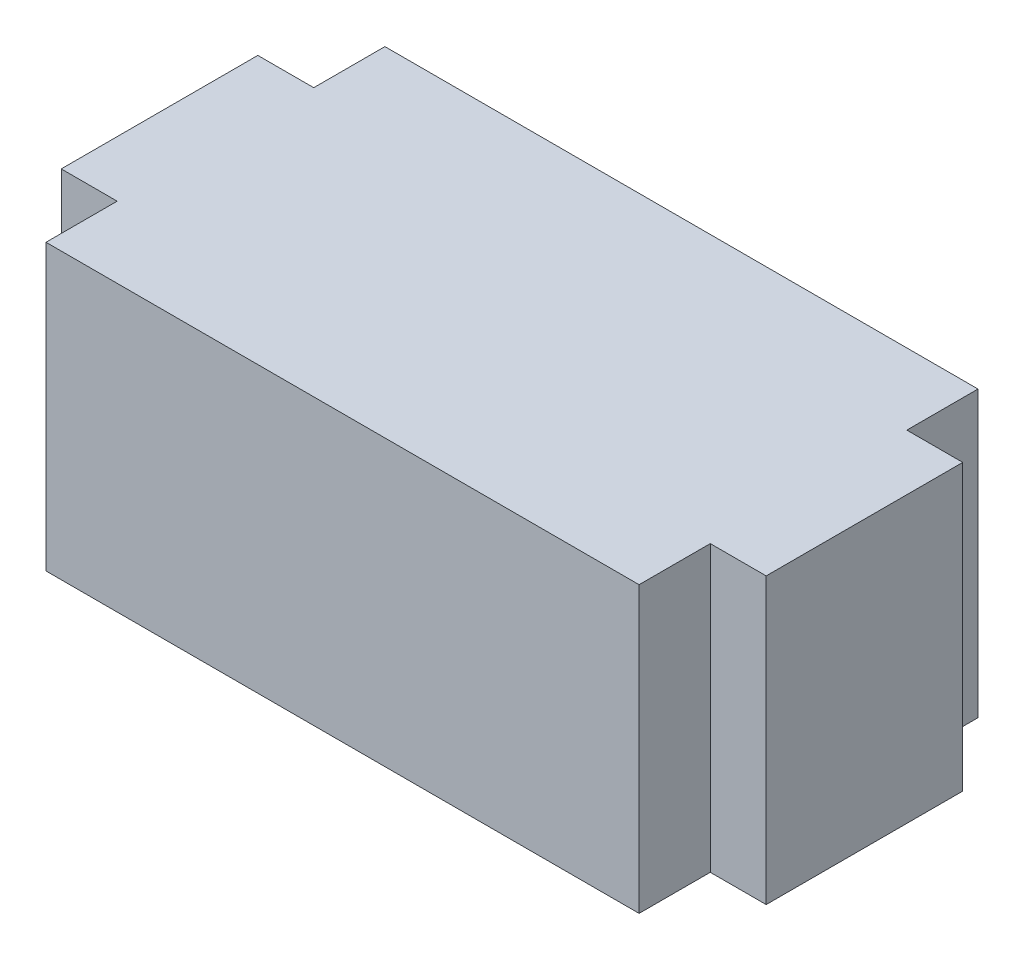
from build123d import *

# Parameters (mm, degrees)
SKETCH1_W           = 5.2
SKETCH1_H           = 2.1
BOSS_EXTRUDE1_DEPTH = 2.5
SKETCH2_W           = 0.4125
SKETCH2_H           = 0.525
CUT_EXTRUDE1_DEPTH  = 3.1


with BuildPart() as part:
    # Sketch1 → Boss-Extrude1 (new body)
    with BuildSketch(Plane.XY):
        with Locations((2.6, 1.05)):
            Rectangle(SKETCH1_W, SKETCH1_H)
    extrude(amount=BOSS_EXTRUDE1_DEPTH)

    # Sketch2 → Cut-Extrude1 (cut, through all)
    with BuildSketch(Plane(origin=(0, 2.1, 0), x_dir=(1, 0, 0), z_dir=(0, 1, 0))):
        with Locations((4.99375, -0.2625)):
            Rectangle(SKETCH2_W, SKETCH2_H)
        with Locations((0.20625, -0.2625)):
            Rectangle(SKETCH2_W, SKETCH2_H)
        with Locations((4.99375, -2.2375)):
            Rectangle(SKETCH2_W, SKETCH2_H)
        with Locations((0.20625, -2.2375)):
            Rectangle(SKETCH2_W, SKETCH2_H)
    extrude(amount=-CUT_EXTRUDE1_DEPTH, mode=Mode.SUBTRACT)


solid = part.part
